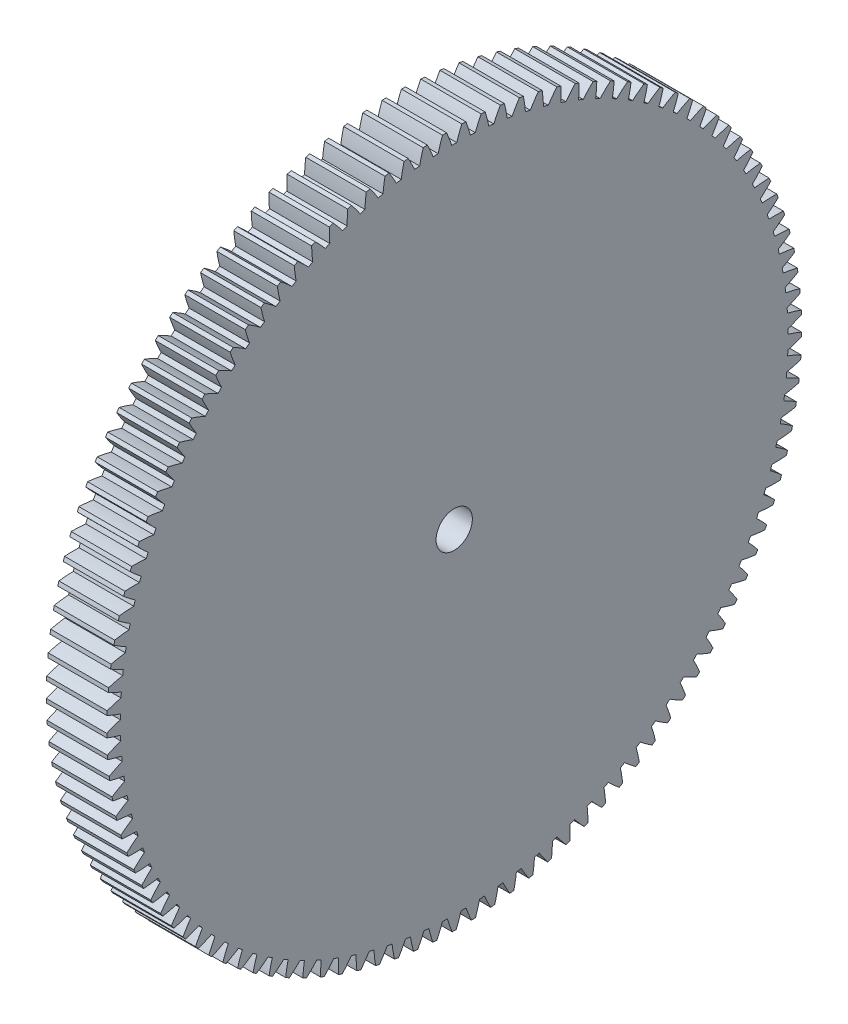
from build123d import *

# Parameters (mm, degrees)
BASPROSKE_W     = 5
BASPROSKE_H     = 28.75
TOOTHCUT_DEPTH  = 41.96492402
TEETHCUTS_COUNT = 113
TEETHCUTS_ANGLE = 356.814159292
BORSKE_R        = 1.5
BORE_DEPTH      = 50.0000508


with BuildPart() as part:
    # BasProSke → Base-Revolve (revolve)
    with BuildSketch(Plane(origin=(0, 0, 0), x_dir=(1, 0, 0), z_dir=(0, 1, 0)), mode=Mode.PRIVATE) as base_revolve_sk:
        with Locations((2.5, 14.375)):
            Rectangle(BASPROSKE_W, BASPROSKE_H)
    revolve(base_revolve_sk.sketch.rotate(Axis((-10, 0, 0), (1, 0, 0)), 180), axis=Axis((-10, 0, 0), (1, 0, 0)))

    # TooCutSke → ToothCut (cut, through all)
    with BuildSketch(Plane(origin=(0, 0, 0), x_dir=(0, 0, -1), z_dir=(1, 0, 0))):
        with BuildLine():
            ThreePointArc((0.205813441, 27.62323328), (0, 27.624), (-0.205813441, 27.62323328))
            ThreePointArc((-0.205813441, 27.62323328), (-0.408612136, 28.201653619), (-0.642475981, 28.76822674))
            ThreePointArc((-0.642475981, 28.76822674), (0, 28.7754), (0.642475981, 28.76822674))
            ThreePointArc((0.642475981, 28.76822674), (0.408612136, 28.201653619), (0.205813441, 27.62323328))
        make_face()
    toothcut = extrude(amount=TOOTHCUT_DEPTH, mode=Mode.SUBTRACT)

    # TeethCuts: ToothCut ×113 about axis
    teethcuts_axis = Axis((-10, 0, 0), (1, 0, 0))
    for i in range(1, TEETHCUTS_COUNT):
        add(toothcut.rotate(teethcuts_axis, i * TEETHCUTS_ANGLE / (TEETHCUTS_COUNT - 1)), mode=Mode.SUBTRACT)

    # BorSke → Bore (cut, symmetric)
    with BuildSketch(Plane(origin=(0, 0, 0), x_dir=(0, 0, -1), z_dir=(1, 0, 0))):
        with Locations(Location((0, 0, 0), (0, 0, 180))):
            Circle(BORSKE_R)
    extrude(amount=BORE_DEPTH, both=True, mode=Mode.SUBTRACT)


solid = part.part
